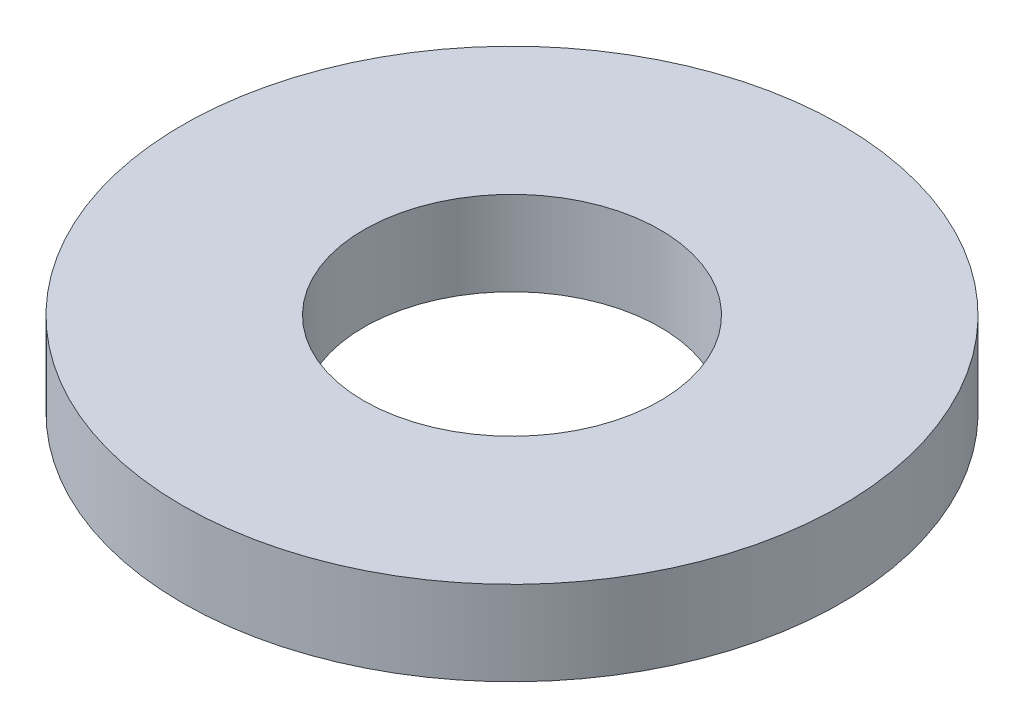
from build123d import *

# Parameters (mm, degrees)
SKETCH1_R           = 7.9375
BOSS_EXTRUDE1_DEPTH = 2.032
SKETCH5_R           = 3.5687
CUT_EXTRUDE1_DEPTH  = 3.032


with BuildPart() as part:
    # Sketch1 → Boss-Extrude1 (new body)
    with BuildSketch(Plane(origin=(0, 0, 0), x_dir=(1, 0, 0), z_dir=(0, 1, 0))):
        Circle(SKETCH1_R)
    extrude(amount=BOSS_EXTRUDE1_DEPTH)

    # Sketch5 → Cut-Extrude1 (cut, through all)
    with BuildSketch(Plane(origin=(0, 2.032, 0), x_dir=(-1, 0, 0), z_dir=(0, 1, 0))):
        Circle(SKETCH5_R)
    extrude(amount=-CUT_EXTRUDE1_DEPTH, mode=Mode.SUBTRACT)


solid = part.part
